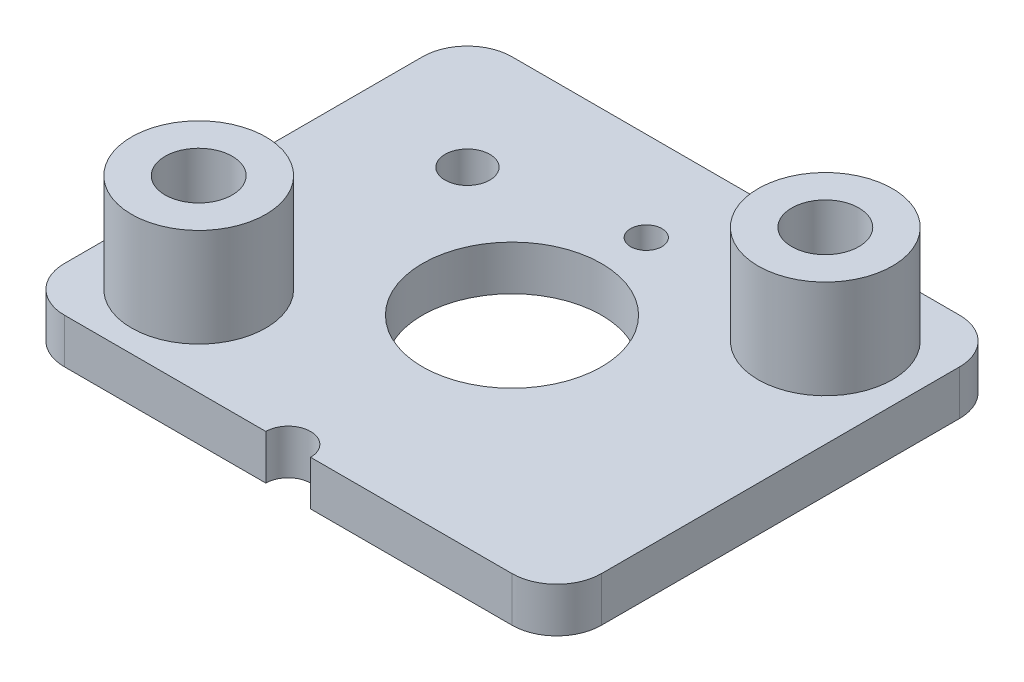
from build123d import *

# Parameters (mm, degrees)
CROQUIS1_R                = 1.5
CROQUIS1_R_2              = 2
CROQUIS1_R_3              = 0.35
CROQUIS1_R_4              = 0.5
SALIENTE_EXTRUIR1_DEPTH   = 1
CROQUIS2_R                = 1.5
SALIENTE_EXTRUIR2_DEPTH   = 2.2
SALIENTE_EXTRUIR2_2_DEPTH = 2.2
REDONDEO1_R               = 1
CROQUIS3_R                = 0.75
CORTAR_EXTRUIR1_DEPTH     = 2.2


with BuildPart() as part:
    # Croquis1 → Saliente-Extruir1 (new body)
    with BuildSketch(Plane(origin=(0, 0, 0), x_dir=(1, 0, 0), z_dir=(0, 1, 0))):
        with BuildLine():
            Line((-6, 5), (6, 5))
            Line((6, 5), (6, -5))
            Line((6, -5), (0.5, -5))
            ThreePointArc((0.5, -5), (0, -4.5), (-0.5, -5))
            Line((-0.5, -5), (-6, -5))
            Line((-6, -5), (-6, 5))
        make_face()
        with Locations((4, 3)):
            Circle(CROQUIS1_R, mode=Mode.SUBTRACT)
        with Locations((-4, -3)):
            Circle(CROQUIS1_R, mode=Mode.SUBTRACT)
        Circle(CROQUIS1_R_2, mode=Mode.SUBTRACT)
        with Locations((0, 3)):
            Circle(CROQUIS1_R_3, mode=Mode.SUBTRACT)
        with Locations((-3.360597475, 2.364908389)):
            Circle(CROQUIS1_R_4, mode=Mode.SUBTRACT)
    extrude(amount=SALIENTE_EXTRUIR1_DEPTH)

    # Redondeo1
    redondeo1_edges = [part.edges().sort_by_distance(p)[0] for p in [
        (-6, 0.5, 5),
        (-6, 0.5, -5),
        (6, 0.5, -5),
        (6, 0.5, 5),
    ]]
    fillet(redondeo1_edges, radius=REDONDEO1_R)


with BuildPart() as body_2:
    # Croquis2 → Saliente-Extruir2 (new body)
    with BuildSketch(Plane(origin=(0, 1, 0), x_dir=(1, 0, 0), z_dir=(0, 1, 0))):
        with Locations((4, 3)):
            Circle(CROQUIS2_R)
    extrude(amount=SALIENTE_EXTRUIR2_DEPTH)


with BuildPart() as body_3:
    # Croquis2 → Saliente-Extruir2 2 (new body)
    with BuildSketch(Plane(origin=(0, 1, 0), x_dir=(1, 0, 0), z_dir=(0, 1, 0))):
        with Locations((-4, -3)):
            Circle(CROQUIS2_R)
    extrude(amount=SALIENTE_EXTRUIR2_2_DEPTH)


with BuildPart() as cortar_extruir1_tool:
    # Croquis3 → Cortar-Extruir1 (new body)
    with BuildSketch(Plane(origin=(0, 3.2, 0), x_dir=(1, 0, 0), z_dir=(0, 1, 0))):
        with Locations((4, 3)):
            Circle(CROQUIS3_R)
        with Locations((-4, -3)):
            Circle(CROQUIS3_R)
    extrude(amount=-CORTAR_EXTRUIR1_DEPTH)


with BuildPart() as body_2_1:
    add(body_2.part)

    # Cortar-Extruir1: cut by cortar_extruir1_tool
    add(cortar_extruir1_tool.part, mode=Mode.SUBTRACT)


with BuildPart() as body_3_1:
    add(body_3.part)

    # Cortar-Extruir1: cut by cortar_extruir1_tool
    add(cortar_extruir1_tool.part, mode=Mode.SUBTRACT)


solid = Compound([part.part, body_2_1.part, body_3_1.part])
